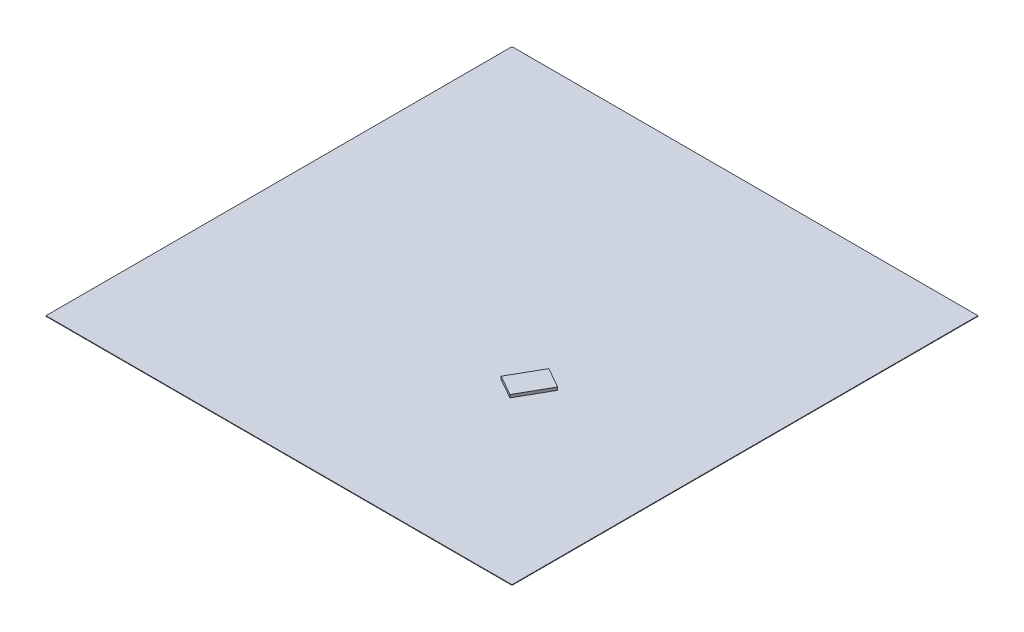
from build123d import *

# Parameters (mm, degrees)
SKETCH1_W           = 80000
SKETCH1_H           = 80000
BOSS_EXTRUDE1_DEPTH = 50
BOSS_EXTRUDE2_DEPTH = 500


with BuildPart() as part:
    # Sketch1 → Boss-Extrude1 (new body, symmetric)
    with BuildSketch(Plane(origin=(0, 0, 0), x_dir=(1, 0, 0), z_dir=(0, 1, 0))):
        with Locations((-3023.622047244, 7496.062992126)):
            Rectangle(SKETCH1_W, SKETCH1_H)
    extrude(amount=BOSS_EXTRUDE1_DEPTH, both=True)

    # Sketch2 → Boss-Extrude2 (add)
    with BuildSketch(Plane(origin=(0, 50, 0), x_dir=(1, 0, 0), z_dir=(0, 1, 0))):
        Polygon((5550.165945197, -2934.336264448), (9030.254688591, -4906.386552372), (11988.330120476, 313.74656272), (8508.241377082, 2285.796850643), align=None)
    extrude(amount=BOSS_EXTRUDE2_DEPTH)


solid = part.part
